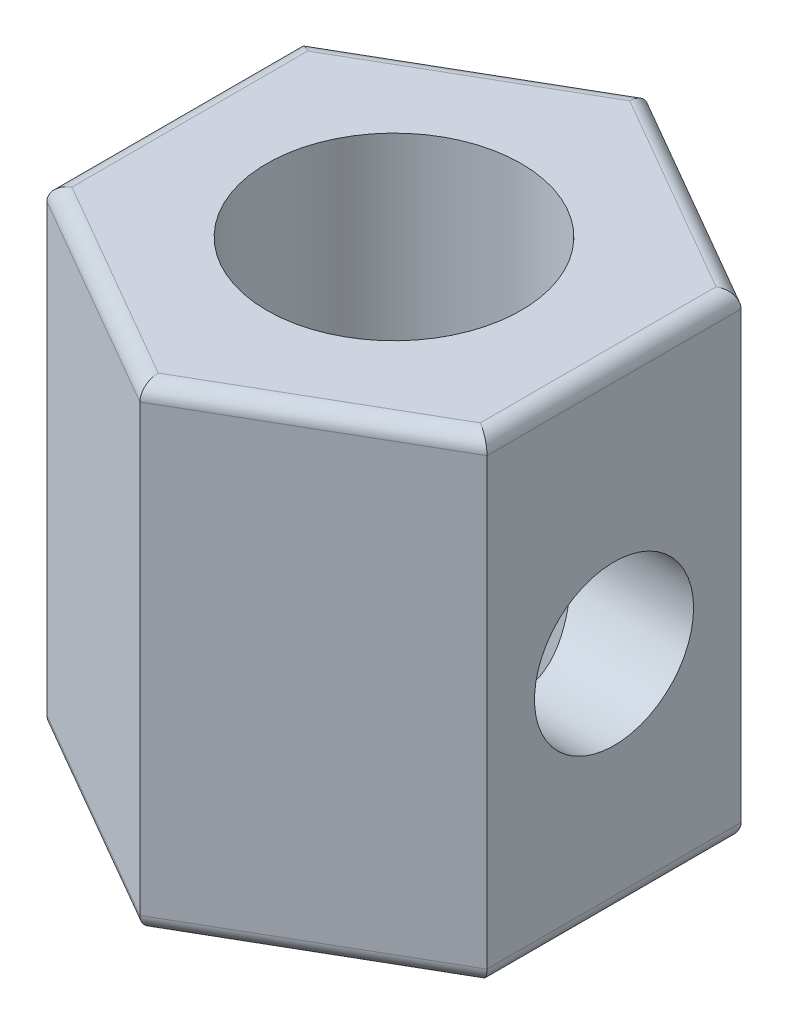
from build123d import *

# Parameters (mm, degrees)
SKETCH1_R                  = 2.0025
BOSS_EXTRUDE1_DEPTH        = 7.5
M3X0_5_TAPPED_HOLE1_REACH  = 10.922
M3X0_5_TAPPED_HOLE1_BORE_R = 1.2525
FILLET1_R                  = 0.25


with BuildPart() as part:
    # Sketch1 → Boss-Extrude1 (new body)
    with BuildSketch(Plane(origin=(0, 0, 0), x_dir=(1, 0, 0), z_dir=(0, 1, 0))):
        Polygon((0, 4), (-3.464101615, 2), (-3.464101615, -2), (0, -4), (3.464101615, -2), (3.464101615, 2), align=None)
        with Locations(Location((0, 0, 0), (0, 0, 270))):
            Circle(SKETCH1_R, mode=Mode.SUBTRACT)
    extrude(amount=BOSS_EXTRUDE1_DEPTH)

    # M3x0.5 Tapped Hole1 bore (on position points) → M3x0.5 Tapped Hole1 (cut, up to next)
    with BuildSketch(Plane(origin=(3.464101615, 3.55, 0), x_dir=(0, 0, 1), z_dir=(1, 0, 0)), mode=Mode.PRIVATE) as m3x0_5_tapped_hole1_sk1:
        Circle(M3X0_5_TAPPED_HOLE1_BORE_R)
    m3x0_5_tapped_hole1_tool1 = extrude(m3x0_5_tapped_hole1_sk1.sketch, amount=-M3X0_5_TAPPED_HOLE1_REACH, mode=Mode.PRIVATE) & part.part
    add(m3x0_5_tapped_hole1_tool1.solids().sort_by_distance((3.464102, 3.55, 0))[0], mode=Mode.SUBTRACT)

    # Fillet1
    fillet1_edges = [part.edges().sort_by_distance(p)[0] for p in [
        (-3.464101615, 7.5, 0),
        (-1.732050808, 7.5, 3),
        (1.732050808, 7.5, 3),
        (3.464101615, 7.5, 0),
        (1.732050808, 7.5, -3),
        (3.464101615, 0, 0),
        (1.732050808, 0, 3),
        (-1.732050808, 0, 3),
        (-1.732050808, 7.5, -3),
        (-3.464101615, 0, 0),
        (-1.732050808, 0, -3),
        (1.732050808, 0, -3),
    ]]
    fillet(fillet1_edges, radius=FILLET1_R)


solid = part.part
